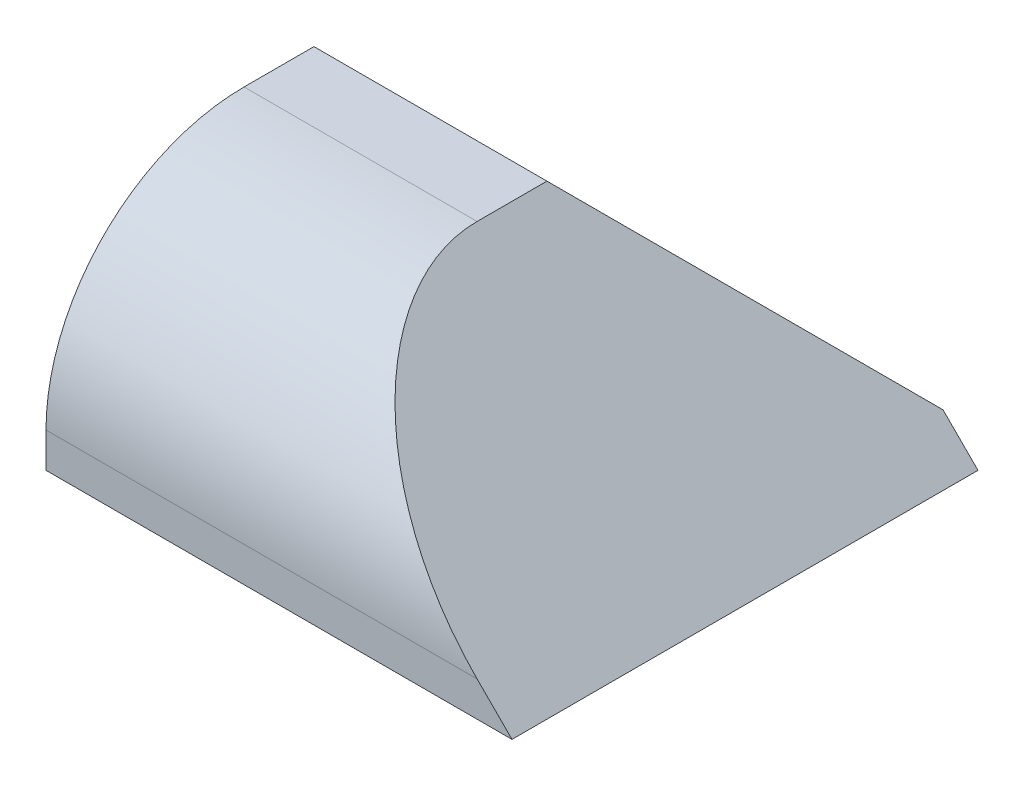
from build123d import *

# Parameters (mm, degrees)
SKETCH1_W           = 20
SKETCH1_H           = 20
BOSS_EXTRUDE1_DEPTH = 10
CUT_EXTRUDE1_DEPTH  = 21
CUT_EXTRUDE2_DEPTH  = 21


with BuildPart() as part:
    # Sketch1 → Boss-Extrude1 (new body)
    with BuildSketch(Plane(origin=(0, 0, 0), x_dir=(1, 0, 0), z_dir=(0, 1, 0))):
        with Locations((10, 10)):
            Rectangle(SKETCH1_W, SKETCH1_H)
    extrude(amount=BOSS_EXTRUDE1_DEPTH)

    # Sketch2 → Cut-Extrude1 (cut, through all)
    with BuildSketch(Plane(origin=(20, 0, 0), x_dir=(0, 0, -1), z_dir=(1, 0, 0))):
        Polygon((20, 1.5), (11.5, 10), (20, 10), align=None)
        with BuildLine():
            Line((0, 1.5), (0, 10))
            Line((0, 10), (8.5, 10))
            ThreePointArc((8.5, 10), (2.48959236, 7.51040764), (0, 1.5))
        make_face()
    extrude(amount=-CUT_EXTRUDE1_DEPTH, mode=Mode.SUBTRACT)

    # Sketch3 → Cut-Extrude2 (cut, through all)
    with BuildSketch(Plane(origin=(0, 0, -20), x_dir=(-1, 0, 0), z_dir=(0, 0, -1))):
        Polygon((-20, 0), (-10, 10), (-20, 10), align=None)
    extrude(amount=-CUT_EXTRUDE2_DEPTH, mode=Mode.SUBTRACT)


solid = part.part
